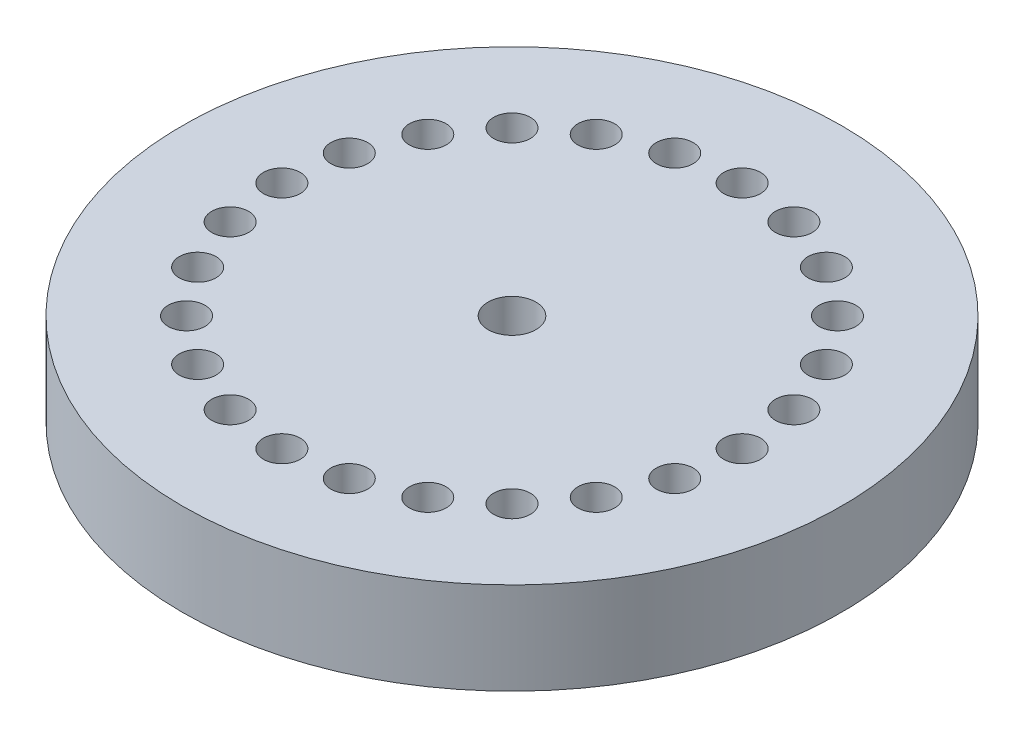
from build123d import *

# Parameters (mm, degrees)
SKETCH1_R                                        = 45.466
BOSS_EXTRUDE1_DEPTH                              = 25.4
SKETCH3_R                                        = 20.32
CUT_EXTRUDE1_DEPTH                               = 12.7
CSK_FOR_1_4_FLAT_HEAD_MACHINE_SCREW1_D           = 6.5278
CSK_FOR_1_4_FLAT_HEAD_MACHINE_SCREW1_DEPTH       = 25.4
CSK_FOR_1_4_FLAT_HEAD_MACHINE_SCREW1_CSINK_D     = 12.8778
CSK_FOR_1_4_FLAT_HEAD_MACHINE_SCREW1_CSINK_ANGLE = 82
CSK_FOR_1_4_FLAT_HEAD_MACHINE_SCREW1_TIP         = 1.961148974
SKETCH8_R                                        = 46.955588052
CUT_EXTRUDE2_DEPTH                               = 12.7
SKETCH4_R                                        = 1.778
CUT_EXTRUDE3_DEPTH                               = 13.7
SKETCH9_R                                        = 2.54
CUT_EXTRUDE4_DEPTH                               = 5.08
CIRPATTERN1_COUNT                                = 24
SKETCH10_R                                       = 22.834776664
BOSS_EXTRUDE2_DEPTH                              = 5.08
SKETCH11_R                                       = 3.302
CUT_EXTRUDE5_DEPTH                               = 13.7


with BuildPart() as part:
    # Sketch1 → Boss-Extrude1 (new body)
    with BuildSketch(Plane(origin=(0, 0, 0), x_dir=(1, 0, 0), z_dir=(0, 1, 0))):
        Circle(SKETCH1_R)
    extrude(amount=BOSS_EXTRUDE1_DEPTH)

    # Sketch3 → Cut-Extrude1 (cut)
    with BuildSketch(Plane.XZ):
        Circle(SKETCH3_R)
    extrude(amount=-CUT_EXTRUDE1_DEPTH, mode=Mode.SUBTRACT)

    # CSK for 1/4 Flat Head Machine Screw1
    with Locations(Plane(origin=(0, 25.4, 0), x_dir=(1, 0, 0), z_dir=(0, 1, 0))):
        with Locations((0, 0)):
            CounterSinkHole(CSK_FOR_1_4_FLAT_HEAD_MACHINE_SCREW1_D / 2, CSK_FOR_1_4_FLAT_HEAD_MACHINE_SCREW1_CSINK_D / 2, depth=CSK_FOR_1_4_FLAT_HEAD_MACHINE_SCREW1_DEPTH, counter_sink_angle=CSK_FOR_1_4_FLAT_HEAD_MACHINE_SCREW1_CSINK_ANGLE)
            with Locations((0, 0, -(CSK_FOR_1_4_FLAT_HEAD_MACHINE_SCREW1_DEPTH + CSK_FOR_1_4_FLAT_HEAD_MACHINE_SCREW1_TIP / 2))):  # 118° drill point
                Cone(0, CSK_FOR_1_4_FLAT_HEAD_MACHINE_SCREW1_D / 2, CSK_FOR_1_4_FLAT_HEAD_MACHINE_SCREW1_TIP, mode=Mode.SUBTRACT)

    # Sketch8 → Cut-Extrude2 (cut)
    with BuildSketch(Plane(origin=(0, 25.4, 0), x_dir=(1, 0, 0), z_dir=(0, 1, 0))):
        Circle(SKETCH8_R)
    extrude(amount=-CUT_EXTRUDE2_DEPTH, mode=Mode.SUBTRACT)

    # Sketch4 → Cut-Extrude3 (cut, through all)
    with BuildSketch(Plane.XZ):
        with Locations((0, 31.75)):
            Circle(SKETCH4_R)
    cut_extrude3 = extrude(amount=-CUT_EXTRUDE3_DEPTH, mode=Mode.SUBTRACT)

    # Sketch9 → Cut-Extrude4 (cut)
    with BuildSketch(Plane(origin=(0, 12.7, 0), x_dir=(1, 0, 0), z_dir=(0, 1, 0))):
        with Locations((0, -31.75)):
            Circle(SKETCH9_R)
    cut_extrude4 = extrude(amount=-CUT_EXTRUDE4_DEPTH, mode=Mode.SUBTRACT)

    # CirPattern1: Cut-Extrude3, Cut-Extrude4 ×24 about axis
    cirpattern1_axis = Axis((0, 0, 0), (0, 1, 0))
    for i in range(1, CIRPATTERN1_COUNT):
        add(cut_extrude3.rotate(cirpattern1_axis, i * 360 / CIRPATTERN1_COUNT), mode=Mode.SUBTRACT)
        add(cut_extrude4.rotate(cirpattern1_axis, i * 360 / CIRPATTERN1_COUNT), mode=Mode.SUBTRACT)

    # Sketch10 → Boss-Extrude2 (add)
    with BuildSketch(Plane(origin=(0, 12.7, 0), x_dir=(1, 0, 0), z_dir=(0, 1, 0))):
        Circle(SKETCH10_R)
    extrude(amount=-BOSS_EXTRUDE2_DEPTH)

    # Sketch11 → Cut-Extrude5 (cut, through all)
    with BuildSketch(Plane(origin=(0, 12.7, 0), x_dir=(1, 0, 0), z_dir=(0, 1, 0))):
        Circle(SKETCH11_R)
    extrude(amount=-CUT_EXTRUDE5_DEPTH, mode=Mode.SUBTRACT)


solid = part.part
